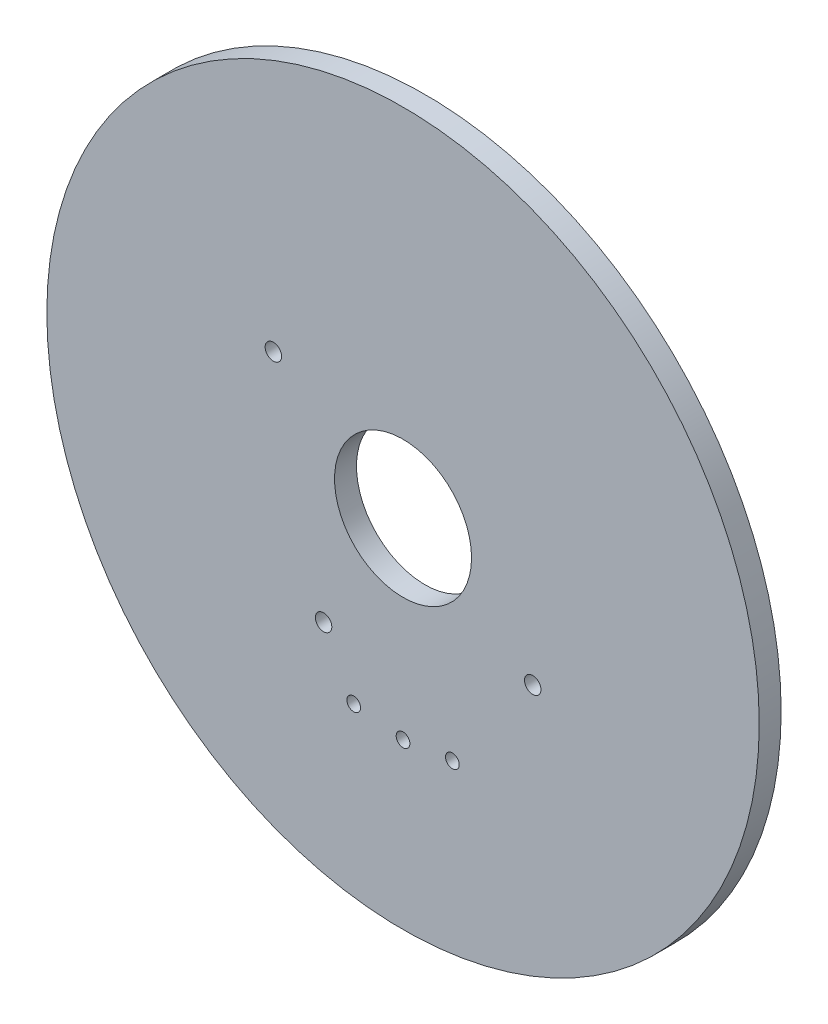
from build123d import *

# Parameters (mm, degrees)
CROQUIS1_R              = 13
CROQUIS1_R_2            = 2.5
SALIENTE_EXTRUIR1_DEPTH = 0.8
CROQUIS2_R              = 0.25
CROQUIS2_R_2            = 0.3
CORTAR_EXTRUIR1_DEPTH   = 1.6


with BuildPart() as part:
    # Croquis1 → Saliente-Extruir1 (new body)
    with BuildSketch(Plane.XY):
        Circle(CROQUIS1_R)
        Circle(CROQUIS1_R_2, mode=Mode.SUBTRACT)
    extrude(amount=SALIENTE_EXTRUIR1_DEPTH)

    # Croquis2 → Cortar-Extruir1 (cut)
    with BuildSketch(Plane.XY.offset(0.8)):
        with Locations((0, -7)):
            Circle(CROQUIS2_R)
        with Locations((-1.8, -6.76461381)):
            Circle(CROQUIS2_R)
        with Locations((1.8, -6.76461381)):
            Circle(CROQUIS2_R)
        with Locations((4.73299588, -2.9)):
            Circle(CROQUIS2_R_2)
        with Locations((-2.9, -4.73299588)):
            Circle(CROQUIS2_R_2)
        with Locations((-4.73299588, 2.9)):
            Circle(CROQUIS2_R_2)
    extrude(amount=-CORTAR_EXTRUIR1_DEPTH, mode=Mode.SUBTRACT)


solid = part.part
